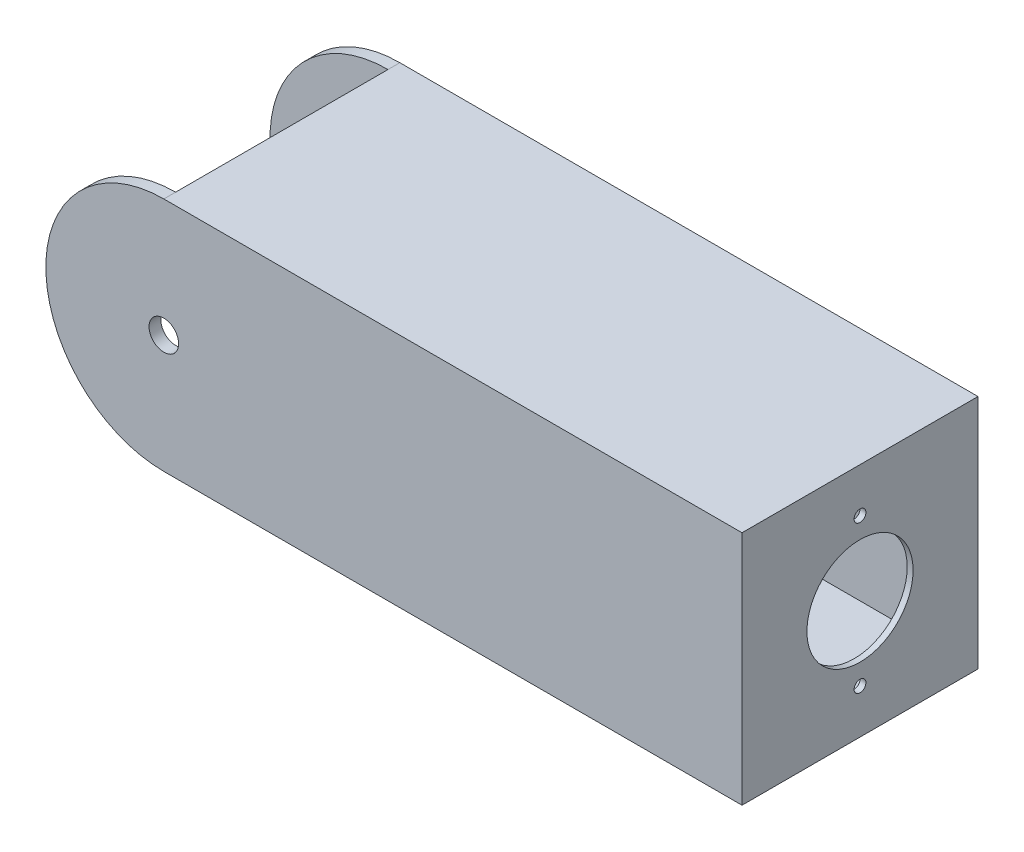
from build123d import *

# Parameters (mm, degrees)
SKETCH2_R           = 3.18135
BOSS_EXTRUDE1_DEPTH = 25.4
SKETCH5_W           = 45.72
SKETCH5_H           = 45.72
CUT_EXTRUDE1_DEPTH  = 72.39
SKETCH6_W           = 45.72
SKETCH6_H           = 45.72
CUT_EXTRUDE2_DEPTH  = 83.82
CUT_EXTRUDE3_REACH  = 151.86
SKETCH8_R           = 11.43
SKETCH8_R_2         = 1.27


with BuildPart() as part:
    # Sketch2 → Boss-Extrude1 (new body, symmetric)
    with BuildSketch(Plane.XY):
        with BuildLine():
            Line((-50.8, 25.4), (73.66, 25.4))
            Line((73.66, 25.4), (73.66, -25.4))
            Line((73.66, -25.4), (-50.8, -25.4))
            ThreePointArc((-50.8, -25.4), (-76.2, 0), (-50.8, 25.4))
        make_face()
        with Locations((-50.8, 0)):
            Circle(SKETCH2_R, mode=Mode.SUBTRACT)
    extrude(amount=BOSS_EXTRUDE1_DEPTH, both=True)

    # Sketch5 → Cut-Extrude1 (cut, symmetric)
    with BuildSketch(Plane(origin=(0, 0, 0), x_dir=(0, 0, -1), z_dir=(1, 0, 0))):
        Rectangle(SKETCH5_W, SKETCH5_H)
    extrude(amount=CUT_EXTRUDE1_DEPTH, both=True, mode=Mode.SUBTRACT)

    # Sketch6 → Cut-Extrude2 (cut, symmetric)
    with BuildSketch(Plane(origin=(0, 0, 0), x_dir=(1, 0, 0), z_dir=(0, 1, 0))):
        with Locations((-73.66, 0)):
            Rectangle(SKETCH6_W, SKETCH6_H)
    extrude(amount=CUT_EXTRUDE2_DEPTH, both=True, mode=Mode.SUBTRACT)

    # Sketch8 → Cut-Extrude3 (cut, up to next)
    with BuildSketch(Plane(origin=(73.66, 0, 0), x_dir=(0, 0, -1), z_dir=(1, 0, 0)), mode=Mode.PRIVATE) as cut_extrude3_sk1:
        Circle(SKETCH8_R)
    cut_extrude3_tool1 = extrude(cut_extrude3_sk1.sketch, amount=-CUT_EXTRUDE3_REACH, mode=Mode.PRIVATE) & part.part
    add(cut_extrude3_tool1.solids().sort_by_distance((73.66, 0, 0))[0], mode=Mode.SUBTRACT)
    # Sketch8 → Cut-Extrude3 (cut, up to next)
    with BuildSketch(Plane(origin=(73.66, 0, 0), x_dir=(0, 0, -1), z_dir=(1, 0, 0)), mode=Mode.PRIVATE) as cut_extrude3_sk2:
        with Locations((0, 15.875)):
            Circle(SKETCH8_R_2)
    cut_extrude3_tool2 = extrude(cut_extrude3_sk2.sketch, amount=-CUT_EXTRUDE3_REACH, mode=Mode.PRIVATE) & part.part
    add(cut_extrude3_tool2.solids().sort_by_distance((73.66, 15.875, 0))[0], mode=Mode.SUBTRACT)
    # Sketch8 → Cut-Extrude3 (cut, up to next)
    with BuildSketch(Plane(origin=(73.66, 0, 0), x_dir=(0, 0, -1), z_dir=(1, 0, 0)), mode=Mode.PRIVATE) as cut_extrude3_sk3:
        with Locations((0, -15.875)):
            Circle(SKETCH8_R_2)
    cut_extrude3_tool3 = extrude(cut_extrude3_sk3.sketch, amount=-CUT_EXTRUDE3_REACH, mode=Mode.PRIVATE) & part.part
    add(cut_extrude3_tool3.solids().sort_by_distance((73.66, -15.875, 0))[0], mode=Mode.SUBTRACT)


solid = part.part
